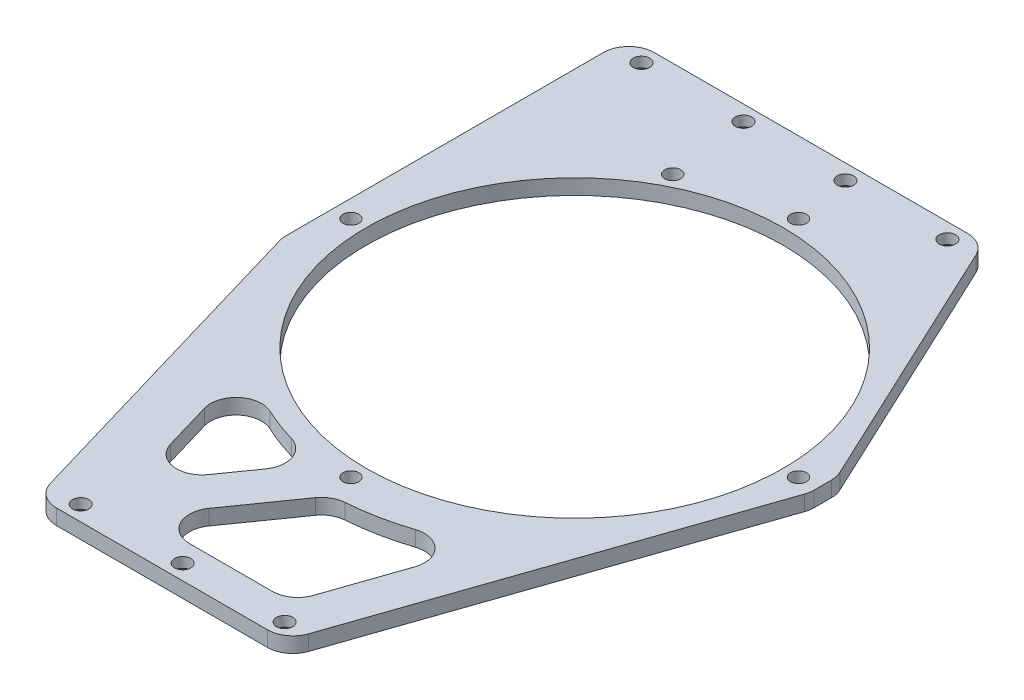
from build123d import *

# Parameters (mm, degrees)
SKETCH_1_W          = 160
SKETCH_1_H          = 136
SKETCH_1_R          = 40.9
SKETCH_1_R_2        = 1.55
SKETCH_1_R_3        = 1.6
EXTRUDE_1_DEPTH     = 3
SKETCH_2_W          = 25
SKETCH_2_H          = 136
EXTRUDE_2_DEPTH     = 3
SKETCH_3_W          = 90
SKETCH_3_H          = 136
CUT_EXTRUDE_1_DEPTH = 4
CUT_EXTRUDE_3_DEPTH = 4
FILLET_1_R          = 5
FILLET_2_R          = 5
CHAMFER_1_SIZE      = 1


with BuildPart() as part:
    # 草图1 → 凸台-拉伸1 (new body)
    with BuildSketch(Plane(origin=(0, 0, 0), x_dir=(1, 0, 0), z_dir=(0, 1, 0))):
        with Locations((-32.38, -10)):
            Rectangle(SKETCH_1_W, SKETCH_1_H)
        Circle(SKETCH_1_R, mode=Mode.SUBTRACT)
        with Locations((0, 43.9)):
            Circle(SKETCH_1_R_2, mode=Mode.SUBTRACT)
        with Locations((43.9, 0)):
            Circle(SKETCH_1_R_2, mode=Mode.SUBTRACT)
        with Locations((0, -43.9)):
            Circle(SKETCH_1_R_2, mode=Mode.SUBTRACT)
        with Locations((-43.9, 0)):
            Circle(SKETCH_1_R_2, mode=Mode.SUBTRACT)
        with Locations((-19.9, 39.130550724)):
            Circle(SKETCH_1_R_2, mode=Mode.SUBTRACT)
        with Locations((18.1, 55)):
            Circle(SKETCH_1_R_3, mode=Mode.SUBTRACT)
        with Locations((-1.9, 55)):
            Circle(SKETCH_1_R_3, mode=Mode.SUBTRACT)
        with Locations((-21.9, 55)):
            Circle(SKETCH_1_R_3, mode=Mode.SUBTRACT)
        with Locations((-41.9, 55)):
            Circle(SKETCH_1_R_3, mode=Mode.SUBTRACT)
        with Locations((18.1, -75)):
            Circle(SKETCH_1_R_3, mode=Mode.SUBTRACT)
        with Locations((-1.9, -75)):
            Circle(SKETCH_1_R_3, mode=Mode.SUBTRACT)
        with Locations((-21.9, -75)):
            Circle(SKETCH_1_R_3, mode=Mode.SUBTRACT)
        with Locations((-41.9, -75)):
            Circle(SKETCH_1_R_3, mode=Mode.SUBTRACT)
    extrude(amount=EXTRUDE_1_DEPTH)

    # 草图2 → 凸台-拉伸2 (add)
    with BuildSketch(Plane(origin=(0, 0, 0), x_dir=(1, 0, 0), z_dir=(0, 1, 0))):
        with Locations((-124.88, -10)):
            Rectangle(SKETCH_2_W, SKETCH_2_H)
    extrude(amount=EXTRUDE_2_DEPTH)

    # 草图3 → 切除-拉伸1 (cut, through all)
    with BuildSketch(Plane(origin=(0, 3, 0), x_dir=(1, 0, 0), z_dir=(0, 1, 0))):
        with Locations((-92.38, -10)):
            Rectangle(SKETCH_3_W, SKETCH_3_H)
    extrude(amount=-CUT_EXTRUDE_1_DEPTH, mode=Mode.SUBTRACT)

    # 草图4 → 切除-拉伸3 (cut, through all)
    with BuildSketch(Plane(origin=(0, 0, 0), x_dir=(1, 0, 0), z_dir=(0, 1, 0))):
        Polygon((47.62, 58), (47.62, 3.843146871), (22.215512532, 58), align=None)
        Polygon((47.62, -1.482721699), (47.62, -78), (21.298056264, -78), align=None)
        with BuildLine():
            Line((-20.395912494, -65.916645202), (-29.90797954, -33.48914391))
            ThreePointArc((-29.90797954, -33.48914391), (-18.489584756, -40.916320162), (-5.369508319, -44.577778998))
            Line((-5.369508319, -44.577778998), (-20.395912494, -65.916645202))
        make_face()
        with BuildLine():
            Line((-14.191049882, -71), (1.385146854, -48.880378151))
            ThreePointArc((1.385146854, -48.880378151), (13.780479279, -46.918103018), (25.268173443, -41.865611316))
            Line((25.268173443, -41.865611316), (15.245943736, -71))
            Line((15.245943736, -71), (-14.191049882, -71))
        make_face()
        Polygon((-47.38, -78), (-47.38, -26), (-47.38, -10), (-27.38, -78), align=None)
    extrude(amount=CUT_EXTRUDE_3_DEPTH, mode=Mode.SUBTRACT)

    # 圆角1
    fillet_1_edges = [part.edges().sort_by_distance(p)[0] for p in [
        (22.215512532, 1.5, -58),
        (47.62, 1.5, -3.843146871),
        (-27.38, 1.5, 78),
        (-47.38, 1.5, 10),
        (47.62, 1.5, 1.482721699),
        (21.298056264, 1.5, 78),
        (-47.38, 1.5, -58),
    ]]
    fillet(fillet_1_edges, radius=FILLET_1_R)

    # 圆角2
    fillet_2_edges = [part.edges().sort_by_distance(p)[0] for p in [
        (-14.191049882, 1.5, 71),
        (15.245943736, 1.5, 71),
        (25.268173443, 1.5, 41.865611316),
        (1.385146854, 1.5, 48.880378151),
        (-5.369508319, 1.5, 44.577778998),
        (-29.90797954, 1.5, 33.48914391),
        (-20.395912494, 1.5, 65.916645202),
    ]]
    fillet(fillet_2_edges, radius=FILLET_2_R)

    # 倒角1
    chamfer_1_edges = [part.edges().sort_by_distance(p)[0] for p in [
        (16.5, 0, -55),
        (-3.5, 0, -55),
        (-23.5, 0, -55),
        (-43.5, 0, -55),
        (16.5, 0, 75),
        (-3.5, 0, 75),
        (-23.5, 0, 75),
    ]]
    chamfer(chamfer_1_edges, length=CHAMFER_1_SIZE)


solid = part.part
